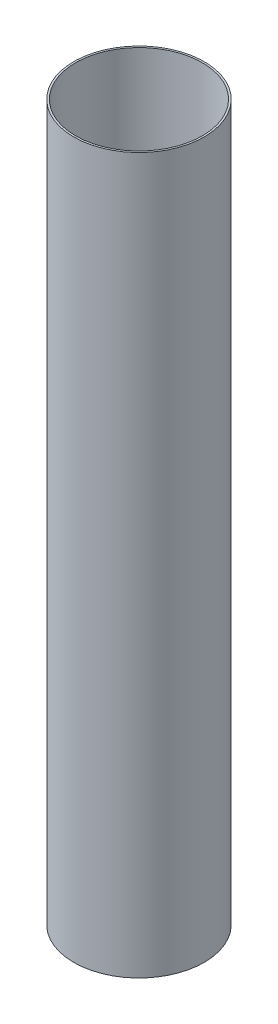
from build123d import *

# Parameters (mm, degrees)
SKETCH2_R           = 51
SKETCH2_R_2         = 49.55
BOSS_EXTRUDE1_DEPTH = 558.8


with BuildPart() as part:
    # Sketch2 → Boss-Extrude1 (new body)
    with BuildSketch(Plane(origin=(0, 0, 0), x_dir=(1, 0, 0), z_dir=(0, 1, 0))):
        Circle(SKETCH2_R)
        Circle(SKETCH2_R_2, mode=Mode.SUBTRACT)
    extrude(amount=BOSS_EXTRUDE1_DEPTH)


solid = part.part
